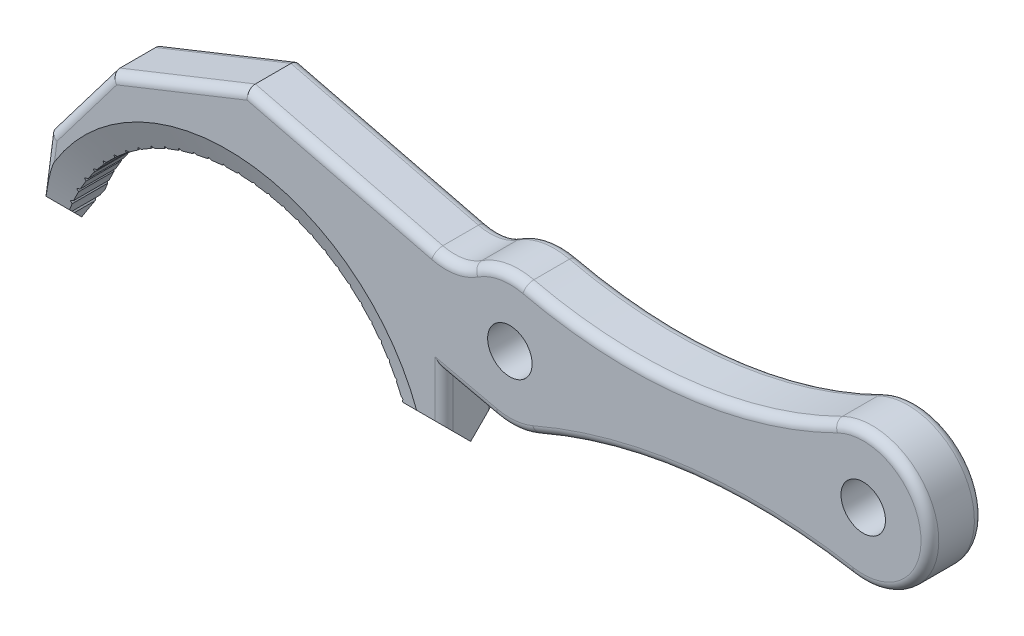
from build123d import *

# Parameters (mm, degrees)
SKETCH1_R           = 3.174999996
BOSS_EXTRUDE1_DEPTH = 3.81
CUT_EXTRUDE1_START  = -28.077464207
CUT_EXTRUDE1_DEPTH  = 129.412136136
CHAMFER1_SIZE       = 1.27
CHAMFER1_SIZE2      = 3.489296323
CUT_EXTRUDE2_DEPTH  = 8.6200001
CIRPATTERN1_COUNT   = 30
CIRPATTERN1_ANGLE   = 140
FILLET1_R           = 1.27


with BuildPart() as part:
    # Sketch1 → Boss-Extrude1 (new body, symmetric)
    with BuildSketch(Plane.XY):
        with BuildLine():
            Line((24.593444248, 0), (30.943444248, 0))
            Line((30.943444248, 0), (30.943444248, 10.16))
            Line((30.943444248, 10.16), (38.22885109, 8.494535917))
            ThreePointArc((38.22885109, 8.494535917), (41.224902571, 8.295125096), (44.134160812, 9.038297782))
            ThreePointArc((44.134160812, 9.038297782), (66.250734646, 14.974648774), (89.13979265, 14.286081463))
            ThreePointArc((89.13979265, 14.286081463), (100.238367866, 25.014604577), (86.57364486, 32.194780425))
            ThreePointArc((86.57364486, 32.194780425), (64.989669624, 25.789695951), (42.511076823, 27.056960645))
            ThreePointArc((42.511076823, 27.056960645), (38.669831505, 27.155366792), (35.102269401, 25.728009095))
            ThreePointArc((35.102269401, 25.728009095), (32.408902751, 24.661086907), (29.513777721, 24.765))
            Line((29.513777721, 24.765), (2.745715563, 31.383672495))
            Line((2.745715563, 31.383672495), (-16.585766286, 23.686929062))
            Line((-16.585766286, 23.686929062), (-25.527743463, 11.903782272))
            Line((-25.527743463, 11.903782272), (-27.077464207, 0))
            Line((-27.077464207, 0), (-24.593444248, 0))
            ThreePointArc((-24.593444248, 0), (0, 19.05), (24.593444248, 0))
        make_face()
        with Locations((40.351533771, 17.78)):
            Circle(SKETCH1_R, mode=Mode.SUBTRACT)
        with Locations((90.809671929, 23.663561305)):
            Circle(SKETCH1_R, mode=Mode.SUBTRACT)
    extrude(amount=BOSS_EXTRUDE1_DEPTH, both=True)

    # Sketch2 → Cut-Extrude1 (cut)
    with BuildSketch(Plane(origin=(0, 0, 0), x_dir=(0, 0, -1), z_dir=(1, 0, 0)).offset(CUT_EXTRUDE1_START)):
        Polygon((0, 0), (3.81, 3.81), (3.81, 0), align=None)
    cut_extrude1 = extrude(amount=CUT_EXTRUDE1_DEPTH, mode=Mode.SUBTRACT)

    # Mirror1: Cut-Extrude1 across plane
    add(cut_extrude1.mirror(Plane.XY), mode=Mode.SUBTRACT)

    # Chamfer1
    chamfer1_edges = [part.edges().sort_by_distance(p)[0] for p in [
        (0, 19.05, -3.81),
        (0, 19.05, 3.81),
    ]]
    chamfer1_side = [part.faces().sort_by_distance(p)[0] for p in [
        (0, 19.05, 0),
    ]]
    chamfer(chamfer1_edges, length=CHAMFER1_SIZE, length2=CHAMFER1_SIZE2, reference=chamfer1_side[0])

    # Sketch4 → Cut-Extrude2 (cut, through all)
    with BuildSketch(Plane.XY.offset(3.81)):
        Polygon((23.938990025, 3.039538145), (22.084245194, -0.445280344), (20.209632779, 4.334116386), align=None)
    cut_extrude2 = extrude(amount=-CUT_EXTRUDE2_DEPTH, mode=Mode.SUBTRACT)

    # CirPattern1: Cut-Extrude2 ×30 about axis
    cirpattern1_axis = Axis((0, -6.35, 0), (0, 0, 1))
    for i in range(1, CIRPATTERN1_COUNT):
        add(cut_extrude2.rotate(cirpattern1_axis, i * CIRPATTERN1_ANGLE / (CIRPATTERN1_COUNT - 1)), mode=Mode.SUBTRACT)

    # Fillet1
    fillet1_edges = [part.edges().sort_by_distance(p)[0] for p in [
        (34.586147669, 9.327267958, -3.81),
        (41.224902571, 8.295125096, -3.81),
        (66.250734646, 14.974648774, -3.81),
        (100.238367866, 25.014604577, -3.81),
        (16.129746642, 28.074336247, -3.81),
        (32.408902751, 24.661086907, -3.81),
        (38.669831505, 27.155366792, -3.81),
        (34.586147669, 9.327267958, 3.81),
        (41.224902571, 8.295125096, 3.81),
        (66.250734646, 14.974648774, 3.81),
        (100.238367866, 25.014604577, 3.81),
        (16.129746642, 28.074336247, 3.81),
        (32.408902751, 24.661086907, 3.81),
        (38.669831505, 27.155366792, 3.81),
        (30.943444248, 6.985, -3.81),
        (30.943444248, 6.985, 3.81),
        (64.989669624, 25.789695951, -3.81),
        (64.989669624, 25.789695951, 3.81),
        (-25.947520852, 8.679369971, -3.81),
        (-25.947520852, 8.679369971, 3.81),
        (-21.056754875, 17.795355667, 3.81),
        (-21.056754875, 17.795355667, -3.81),
        (-6.920025362, 27.535300778, -3.81),
        (-6.920025362, 27.535300778, 3.81),
    ]]
    fillet(fillet1_edges, radius=FILLET1_R)


solid = part.part
